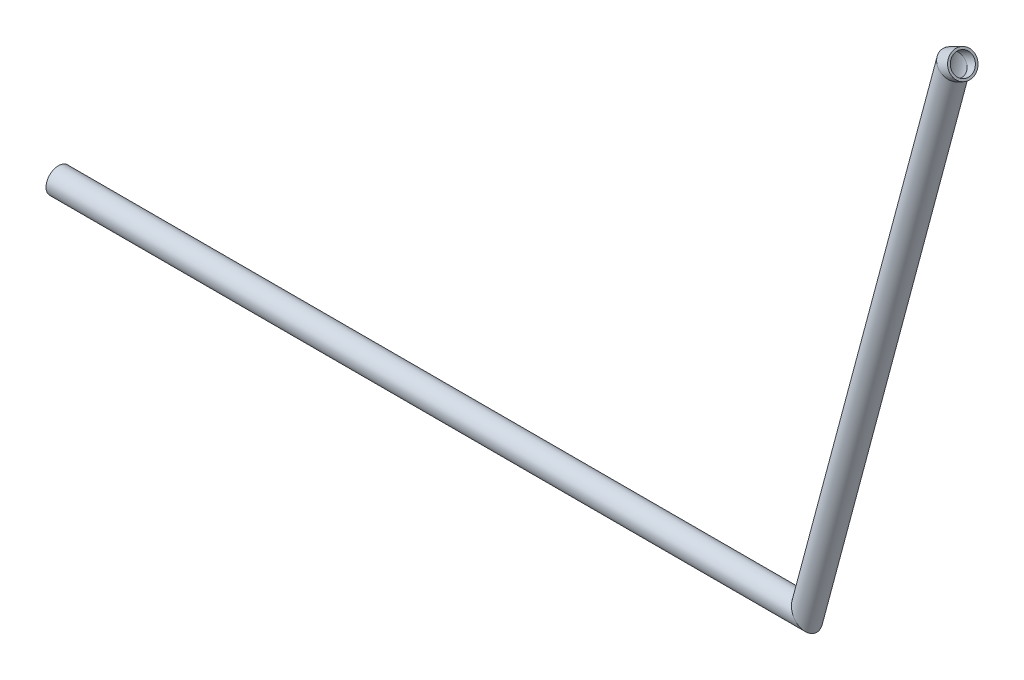
from build123d import *

# Parameters (mm, degrees)
SKETCH1_ON_SEGMENT_1_R                           = 9.525
SKETCH1_ON_SEGMENT_1_R_2                         = 7.874
AL_ROUND_TUBING_AL_RND_TUBE_0_75_OD_X_0_DEPTH    = 16.568525489
SKETCH1_ON_SEGMENT_2_R                           = 9.525
SKETCH1_ON_SEGMENT_2_R_2                         = 7.874
AL_ROUND_TUBING_AL_RND_TUBE_0_75_OD_3_DEPTH      = 449.437929737
SKETCH1_R                                        = 9.525
SKETCH1_R_2                                      = 7.874
AL_ROUND_TUBING_AL_RND_TUBE_0_75_OD_5_DEPTH      = 570
AL_ROUND_TUBING_AL_RND_TUBE_0_75_OD_5_DEPTH_BACK = 11.347512999


with BuildPart() as part:
    # Sketch1 on segment 1 (carried to segment 1) → Al round tubing AL RND TUBE 0.75 OD X 0.065 WALL(1) (new body)
    with BuildSketch(Plane(origin=(715.67660278, 365.261024414, 100.947050286), x_dir=(-0.129892659, -0.035413668, 0.990895438), z_dir=(-0.853148239, -0.505238537, -0.129892659))):
        Circle(SKETCH1_ON_SEGMENT_1_R)
        Circle(SKETCH1_ON_SEGMENT_1_R_2, mode=Mode.SUBTRACT)
    extrude(amount=AL_ROUND_TUBING_AL_RND_TUBE_0_75_OD_X_0_DEPTH)

    # Al round tubing AL RND TUBE 0.75 OD  2
    split(bisect_by=Plane(origin=(707.14512039, 360.208639043, 99.648123697), x_dir=(-0.798077917, 0.602554262, 0), z_dir=(0.601064457, 0.796104684, 0.070276955)), keep=Keep.TOP)


with BuildPart() as body_2:
    # Sketch1 on segment 2 (carried to segment 2) → Al round tubing AL RND TUBE 0.75 OD  3 (new body)
    with BuildSketch(Plane(origin=(708.838467642, 366.555142189, 99.648123697), x_dir=(0, 0, 1), z_dir=(-0.257797165, -0.966199059, 0))):
        Circle(SKETCH1_ON_SEGMENT_2_R)
        Circle(SKETCH1_ON_SEGMENT_2_R_2, mode=Mode.SUBTRACT)
    extrude(amount=AL_ROUND_TUBING_AL_RND_TUBE_0_75_OD_3_DEPTH)

    # Al round tubing AL RND TUBE 0.75 OD 3 mi
    split(bisect_by=Plane(origin=(707.14512039, 360.208639043, 99.648123697), x_dir=(0.798077917, -0.602554262, 0), z_dir=(-0.601064457, -0.796104684, -0.070276955)), keep=Keep.TOP)

    # Al round tubing AL RND TUBE 0.75 OD  4
    split(bisect_by=Plane(origin=(595.9, -56.727406192, 99.648123697), x_dir=(-0.60918094, 0.793031262, 0), z_dir=(0.793031262, 0.60918094, 0)), keep=Keep.TOP)


with BuildPart() as body_3:
    # Sketch1 → Al round tubing AL RND TUBE 0.75 OD  5 (new, two sides)
    with BuildSketch(Plane(origin=(595.9, -56.727406192, 99.648123697), x_dir=(0, 0, 1), z_dir=(-1, 0, 0))) as al_round_tubing_al_rnd_tube_0_75_od_5_sk:
        Circle(SKETCH1_R)
        Circle(SKETCH1_R_2, mode=Mode.SUBTRACT)
    extrude(amount=AL_ROUND_TUBING_AL_RND_TUBE_0_75_OD_5_DEPTH)
    extrude(al_round_tubing_al_rnd_tube_0_75_od_5_sk.sketch, amount=-AL_ROUND_TUBING_AL_RND_TUBE_0_75_OD_5_DEPTH_BACK)

    # Al round tubing AL RND TUBE 0.75 OD 5 mi
    split(bisect_by=Plane(origin=(595.9, -56.727406192, 99.648123697), x_dir=(0.60918094, -0.793031262, 0), z_dir=(-0.793031262, -0.60918094, 0)), keep=Keep.TOP)


solid = Compound([part.part, body_2.part, body_3.part])
